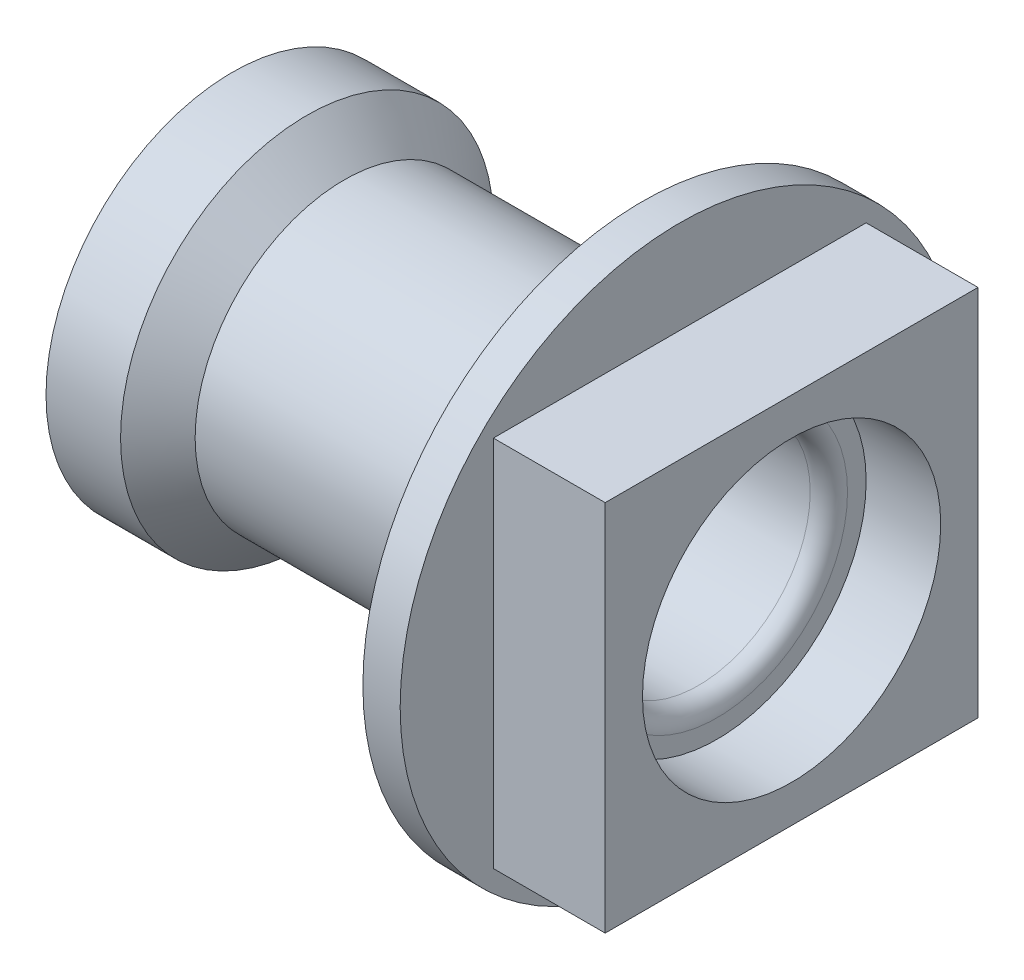
from build123d import *

# Parameters (mm, degrees)
RESSALTO_EXTRUS_O1_DEPTH = 30


with BuildPart() as part:
    # Esboço1 → Revolução1 (revolve)
    with BuildSketch(Plane.XY):
        with BuildLine():
            Line((0, 40), (10, 30))
            Line((10, 30), (125, 30))
            ThreePointArc((125, 30), (128.535533906, 31.464466094), (130, 35))
            Line((130, 35), (130, 40))
            Line((130, 40), (150, 40))
            Line((150, 40), (150, 50))
            Line((150, 50), (120, 50))
            Line((120, 50), (120, 75))
            Line((120, 75), (110, 75))
            Line((110, 75), (110, 50))
            ThreePointArc((110, 50), (107.071067812, 42.928932188), (100, 40))
            Line((100, 40), (30, 40))
            Line((30, 40), (20, 50))
            Line((20, 50), (0, 50))
            Line((0, 50), (0, 40))
        make_face()
    revolve(axis=Axis((0, 0, 0), (1, 0, 0)))

    # Esboço2 → Ressalto-extrusão1 (add)
    with BuildSketch(Plane(origin=(150, 0, 0), x_dir=(0, 0, -1), z_dir=(1, 0, 0))):
        with BuildLine():
            Line((-50, 50), (-50, 2.4e-08))
            ThreePointArc((-50, 2.4e-08), (-35.355339059, 35.35533906), (-2.3e-08, 50))
            Line((-2.3e-08, 50), (-50, 50))
        make_face()
        with BuildLine():
            Line((-50, 2.4e-08), (-50, -50))
            Line((-50, -50), (2.3e-08, -50))
            ThreePointArc((2.3e-08, -50), (-35.35533906, -35.355339059), (-50, 2.4e-08))
        make_face()
        with BuildLine():
            ThreePointArc((50, 0), (35.355339067, -35.355339051), (2.3e-08, -50))
            Line((2.3e-08, -50), (50, -50))
            Line((50, -50), (50, 0))
        make_face()
        with BuildLine():
            ThreePointArc((-2.3e-08, 50), (35.355339051, 35.355339067), (50, 0))
            Line((50, 0), (50, 50))
            Line((50, 50), (-2.3e-08, 50))
        make_face()
    extrude(amount=-RESSALTO_EXTRUS_O1_DEPTH)


solid = part.part
